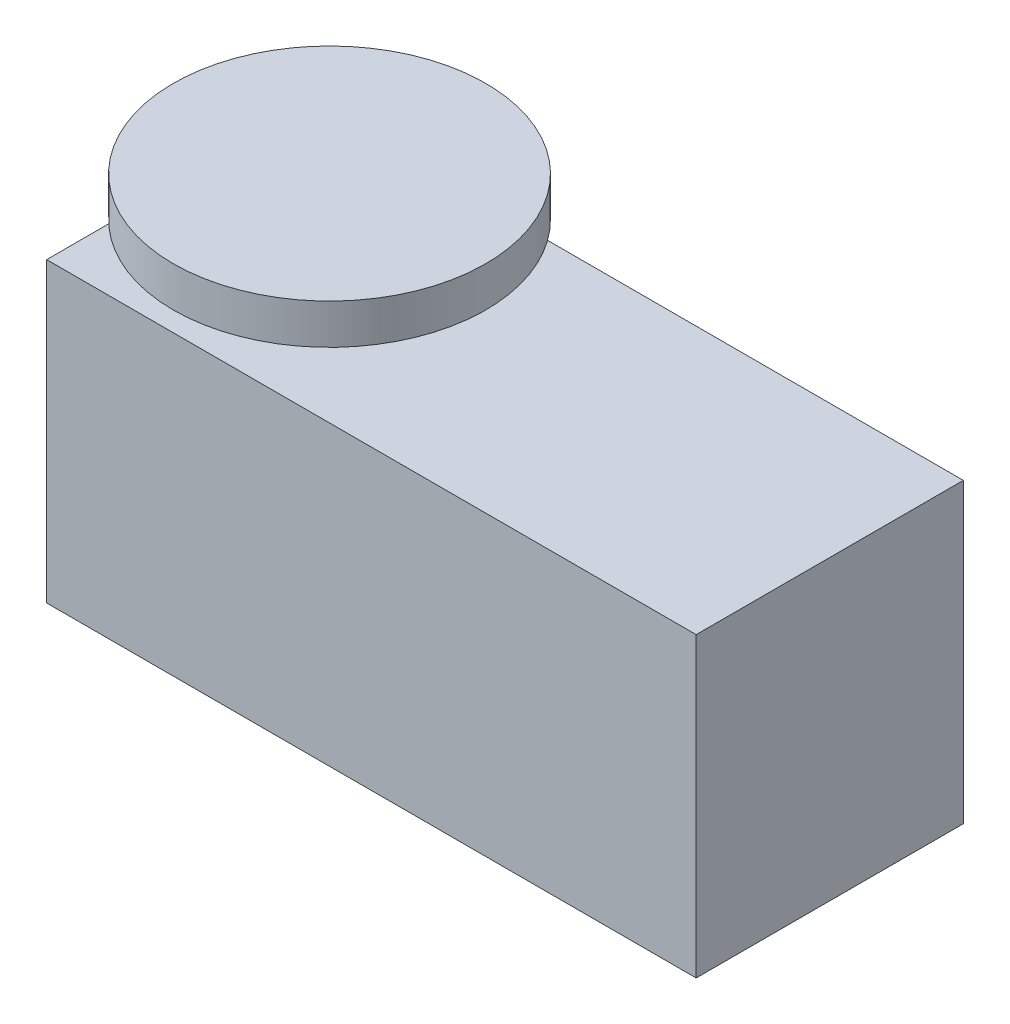
from build123d import *

# Parameters (mm, degrees)
SKETCH1_W           = 48.62
SKETCH1_H           = 22.26
BOSS_EXTRUDE1_DEPTH = 20
SKETCH2_R           = 1.876835713
BOSS_EXTRUDE2_DEPTH = 2.565394694
SKETCH3_R           = 11.694189136
BOSS_EXTRUDE3_DEPTH = 3


with BuildPart() as part:
    # Sketch1 → Boss-Extrude1 (new body)
    with BuildSketch(Plane.XY):
        Rectangle(SKETCH1_W, SKETCH1_H)
    extrude(amount=BOSS_EXTRUDE1_DEPTH)

    # Sketch2 → Boss-Extrude2 (add)
    with BuildSketch(Plane(origin=(0, 11.13, 0), x_dir=(1, 0, 0), z_dir=(0, 1, 0))):
        with Locations((-13.737467658, -9.398056281)):
            Circle(SKETCH2_R)
    extrude(amount=BOSS_EXTRUDE2_DEPTH)

    # Sketch3 → Boss-Extrude3 (add)
    with BuildSketch(Plane(origin=(0, 13.695394694, 0), x_dir=(1, 0, 0), z_dir=(0, 1, 0))):
        with Locations((-13.737467658, -9.398056281)):
            Circle(SKETCH3_R)
    extrude(amount=BOSS_EXTRUDE3_DEPTH)


solid = part.part
